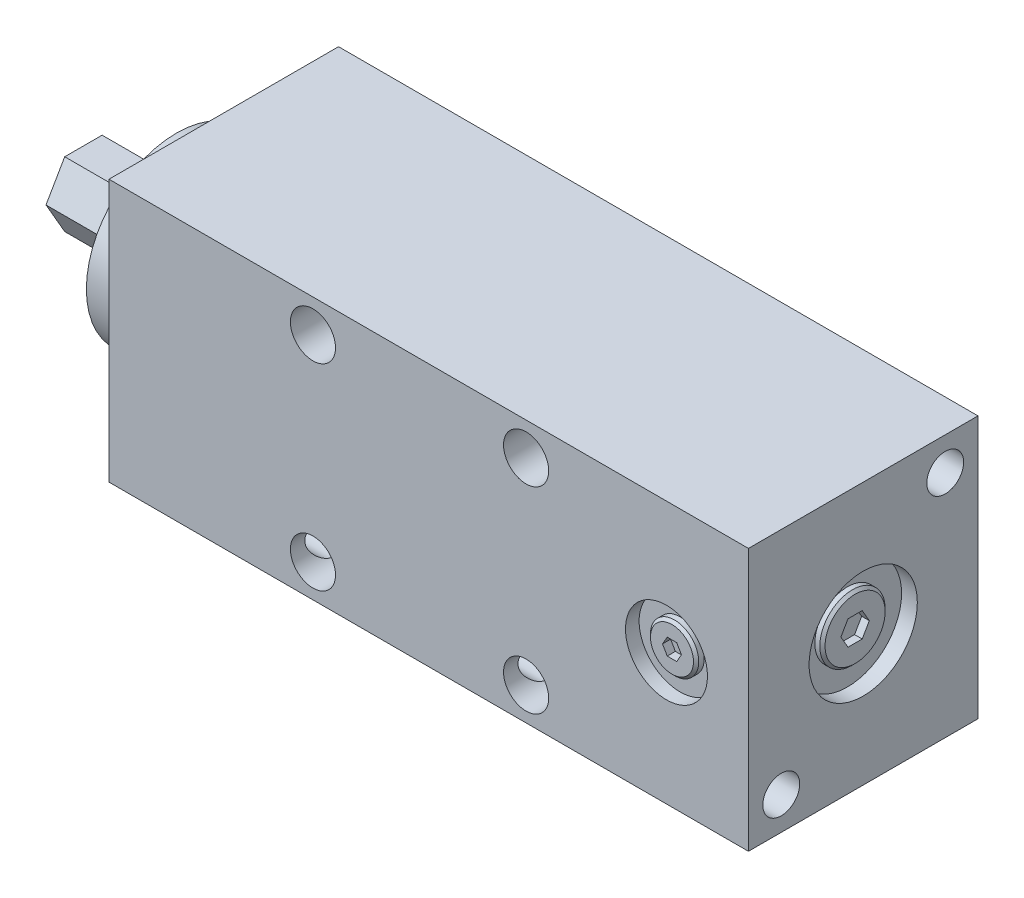
from build123d import *

# Parameters (mm, degrees)
SKETCH1_W           = 123.825
SKETCH1_H           = 44.45
BOSS_EXTRUDE1_DEPTH = 50.8
SKETCH2_R           = 17.4625
BOSS_EXTRUDE2_DEPTH = 9.144
BOSS_EXTRUDE3_DEPTH = 18.034
SKETCH4_R           = 4.3688
CUT_EXTRUDE1_DEPTH  = 45.45
SKETCH5_R           = 3.5687
CUT_EXTRUDE2_DEPTH  = 124.825
SKETCH6_R           = 10.4775
CUT_EXTRUDE3_DEPTH  = 0.508
SKETCH7_R           = 10.4775
CUT_EXTRUDE4_DEPTH  = 3.048
SKETCH8_R           = 7.9375
CUT_EXTRUDE5_DEPTH  = 2.6416
SKETCH9_R           = 6.0706
BOSS_EXTRUDE4_DEPTH = 1.4732
CUT_EXTRUDE6_DEPTH  = 1.4732
SKETCH11_R          = 6.3246
BOSS_EXTRUDE5_DEPTH = 1.4732
SKETCH12_R          = 4.6736
BOSS_EXTRUDE6_DEPTH = 1.5748
CHAMFER1_SIZE       = 0.508
CHAMFER2_SIZE       = 0.508
CHAMFER3_SIZE       = 0.508
SKETCH13_R          = 2.6543
CUT_EXTRUDE7_DEPTH  = 12.7


with BuildPart() as part:
    # Sketch1 → Boss-Extrude1 (new body)
    with BuildSketch(Plane(origin=(0, 0, 0), x_dir=(1, 0, 0), z_dir=(0, 1, 0))):
        with Locations((-61.9125, 22.225)):
            Rectangle(SKETCH1_W, SKETCH1_H)
    extrude(amount=BOSS_EXTRUDE1_DEPTH)

    # Sketch2 → Boss-Extrude2 (add)
    with BuildSketch(Plane.ZY.offset(123.825)):
        with Locations(Location((-22.225, 25.4, 0), (0, 0, 180))):  # turned: the seam where the file's is
            Circle(SKETCH2_R)
    extrude(amount=BOSS_EXTRUDE2_DEPTH)

    # Sketch3 → Boss-Extrude3 (add)
    with BuildSketch(Plane.ZY.offset(132.969)):
        Polygon((-29.469360238, 25.4), (-25.847180119, 19.1262), (-18.602819881, 19.1262), (-14.980639762, 25.4), (-18.602819881, 31.6738), (-25.847180119, 31.6738), align=None)
    extrude(amount=BOSS_EXTRUDE3_DEPTH)

    # Sketch4 → Cut-Extrude1 (cut, through all)
    with BuildSketch(Plane(origin=(0, 0, -44.45), x_dir=(-1, 0, 0), z_dir=(0, 0, -1))):
        with Locations((84.328, 6.35)):
            Circle(SKETCH4_R)
        with Locations((43.053, 6.35)):
            Circle(SKETCH4_R)
        with Locations((43.053, 44.45)):
            Circle(SKETCH4_R)
        with Locations((84.328, 44.45)):
            Circle(SKETCH4_R)
    extrude(amount=-CUT_EXTRUDE1_DEPTH, mode=Mode.SUBTRACT)

    # Sketch5 → Cut-Extrude2 (cut, through all)
    with BuildSketch(Plane.ZY.offset(123.825)):
        with Locations((-6.35, 6.35)):
            Circle(SKETCH5_R)
        with Locations((-38.1, 44.45)):
            Circle(SKETCH5_R)
    extrude(amount=-CUT_EXTRUDE2_DEPTH, mode=Mode.SUBTRACT)

    # Sketch6 → Cut-Extrude3 (cut)
    with BuildSketch(Plane.XZ):
        with Locations(Location((-15.875, -22.225, 0), (0, 0, 270))):  # turned: the seam where the file's is
            Circle(SKETCH6_R)
    extrude(amount=-CUT_EXTRUDE3_DEPTH, mode=Mode.SUBTRACT)

    # Sketch7 → Cut-Extrude4 (cut)
    with BuildSketch(Plane(origin=(0, 0, 0), x_dir=(0, 0, -1), z_dir=(1, 0, 0))):
        with Locations((22.225, 25.4)):
            Circle(SKETCH7_R)
    extrude(amount=-CUT_EXTRUDE4_DEPTH, mode=Mode.SUBTRACT)

    # Sketch8 → Cut-Extrude5 (cut)
    with BuildSketch(Plane.XY):
        with Locations((-15.875, 25.4)):
            Circle(SKETCH8_R)
    extrude(amount=-CUT_EXTRUDE5_DEPTH, mode=Mode.SUBTRACT)

    # Sketch9 → Boss-Extrude4 (add)
    with BuildSketch(Plane.XZ.offset(-0.508)):
        with Locations(Location((-15.875, -22.225, 0), (0, 0, 270))):  # turned: the seam where the file's is
            Circle(SKETCH9_R)
    extrude(amount=BOSS_EXTRUDE4_DEPTH)

    # Sketch10 → Cut-Extrude6 (cut)
    with BuildSketch(Plane.XZ.offset(0.9652)):
        Polygon((-15.875, -19.475369343), (-18.25625, -20.850184671), (-18.25625, -23.599815329), (-15.875, -24.974630657), (-13.49375, -23.599815329), (-13.49375, -20.850184671), align=None)
    extrude(amount=-CUT_EXTRUDE6_DEPTH, mode=Mode.SUBTRACT)

    # Sketch11 → Boss-Extrude5 (add)
    with BuildSketch(Plane(origin=(-3.048, 0, 0), x_dir=(0, 0, -1), z_dir=(1, 0, 0))):
        with Locations((22.225, 25.4)):
            Circle(SKETCH11_R)
        Polygon((19.475369343, 25.4), (20.850184671, 23.01875), (23.599815329, 23.01875), (24.974630657, 25.4), (23.599815329, 27.78125), (20.850184671, 27.78125), align=None, mode=Mode.SUBTRACT)
    extrude(amount=BOSS_EXTRUDE5_DEPTH)

    # Sketch12 → Boss-Extrude6 (add)
    with BuildSketch(Plane.XY.offset(-2.6416)):
        with Locations((-15.875, 25.4)):
            Circle(SKETCH12_R)
        Polygon((-17.708087105, 25.4), (-16.791543552, 23.8125), (-14.958456448, 23.8125), (-14.041912895, 25.4), (-14.958456448, 26.9875), (-16.791543552, 26.9875), align=None, mode=Mode.SUBTRACT)
    extrude(amount=BOSS_EXTRUDE6_DEPTH)

    # Chamfer1
    chamfer1_edges = [part.edges().sort_by_distance(p)[0] for p in [
        (-15.875, -0.9652, -16.1544),
    ]]
    chamfer(chamfer1_edges, length=CHAMFER1_SIZE)

    # Chamfer2
    chamfer2_edges = [part.edges().sort_by_distance(p)[0] for p in [
        (-1.5748, 25.4, -15.9004),
    ]]
    chamfer(chamfer2_edges, length=CHAMFER2_SIZE)

    # Chamfer3
    chamfer3_edges = [part.edges().sort_by_distance(p)[0] for p in [
        (-20.5486, 25.4, -1.0668),
    ]]
    chamfer(chamfer3_edges, length=CHAMFER3_SIZE)

    # Sketch13 → Cut-Extrude7 (cut)
    with BuildSketch(Plane.ZY.offset(151.003)):
        with Locations((-22.225, 25.4)):
            Circle(SKETCH13_R)
    extrude(amount=-CUT_EXTRUDE7_DEPTH, mode=Mode.SUBTRACT)


solid = part.part
